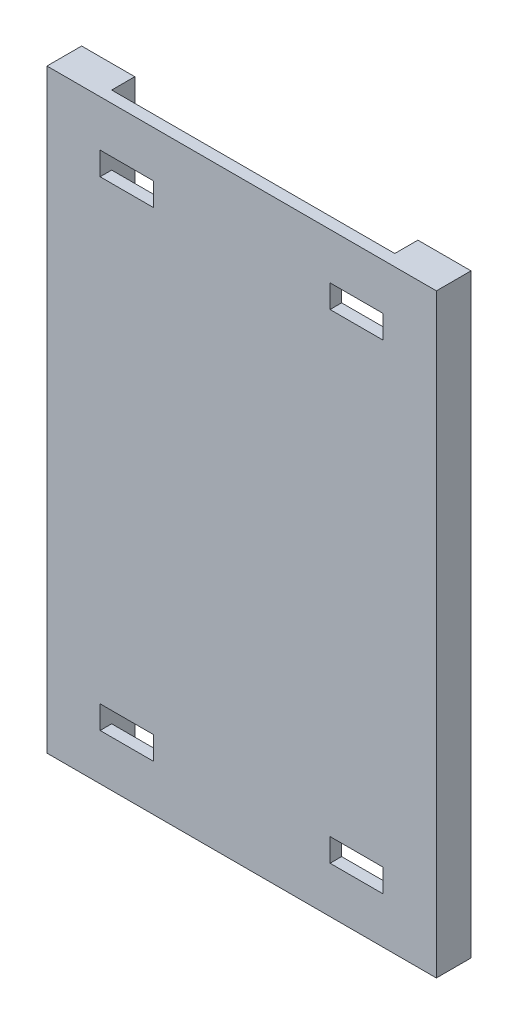
from build123d import *

# Parameters (mm, degrees)
SKETCH1_W           = 337
SKETCH1_H           = 515
SKETCH1_W_2         = 46
SKETCH1_H_2         = 20
BOSS_EXTRUDE1_DEPTH = 10
SKETCH2_W           = 46
SKETCH2_H           = 515
BOSS_EXTRUDE2_DEPTH = 20


with BuildPart() as part:
    # Sketch1 → Boss-Extrude1 (new body)
    with BuildSketch(Plane.XY):
        with Locations((-99.5, -207.5)):
            Rectangle(SKETCH1_W, SKETCH1_H)
        with Locations((-199, -415)):
            Rectangle(SKETCH1_W_2, SKETCH1_H_2, mode=Mode.SUBTRACT)
        with Locations((0, -415)):
            Rectangle(SKETCH1_W_2, SKETCH1_H_2, mode=Mode.SUBTRACT)
        with Locations((-199, 0)):
            Rectangle(SKETCH1_W_2, SKETCH1_H_2, mode=Mode.SUBTRACT)
        Rectangle(SKETCH1_W_2, SKETCH1_H_2, mode=Mode.SUBTRACT)
    extrude(amount=-BOSS_EXTRUDE1_DEPTH)

    # Sketch2 → Boss-Extrude2 (add)
    with BuildSketch(Plane(origin=(0, 0, -10), x_dir=(-1, 0, 0), z_dir=(0, 0, -1))):
        with Locations((245, -207.5)):
            Rectangle(SKETCH2_W, SKETCH2_H)
        with Locations((-46, -207.5)):
            Rectangle(SKETCH2_W, SKETCH2_H)
    extrude(amount=BOSS_EXTRUDE2_DEPTH)


solid = part.part
